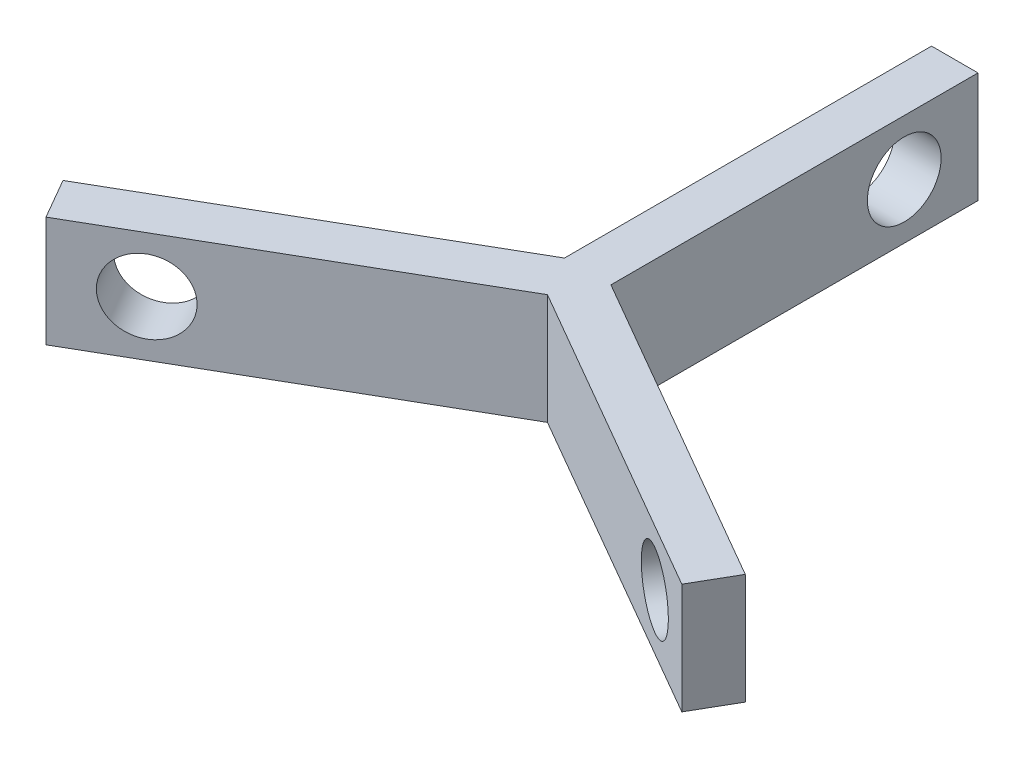
from build123d import *

# Parameters (mm, degrees)
SALIENTE_EXTRUIR1_DEPTH = 5.9535
CROQUIS2_R              = 3.969
CORTAR_EXTRUIR1_DEPTH   = 5
MATRIZC1_COUNT          = 3


with BuildPart() as part:
    # Croquis1 → Saliente-Extruir1 (new body, symmetric)
    with BuildSketch(Plane(origin=(0, 0, 0), x_dir=(1, 0, 0), z_dir=(0, 1, 0))):
        Polygon((-2.5, 40.9535), (2.5, 40.9535), (2.5, 1.443375673), (36.716771374, -18.311686491), (34.216771374, -22.641813509), (0, -2.886751346), (-34.216771374, -22.641813509), (-36.716771374, -18.311686491), (-2.5, 1.443375673), align=None)
    extrude(amount=SALIENTE_EXTRUIR1_DEPTH, both=True)

    # Croquis2 → Cortar-Extruir1 (cut)
    with BuildSketch(Plane(origin=(-1.25, 0, 2.165063509), x_dir=(0.866025404, 0, 0.5), z_dir=(-0.5, 0, 0.866025404))):
        with Locations((33.0155, 0)):
            Circle(CROQUIS2_R)
    cortar_extruir1 = extrude(amount=-CORTAR_EXTRUIR1_DEPTH, mode=Mode.SUBTRACT)

    # MatrizC1: Cortar-Extruir1 ×3 about axis
    matrizc1_axis = Axis((0, 5.9535, 0), (0, 1, 0))
    for i in range(1, MATRIZC1_COUNT):
        add(cortar_extruir1.rotate(matrizc1_axis, i * 360 / MATRIZC1_COUNT), mode=Mode.SUBTRACT)


solid = part.part
